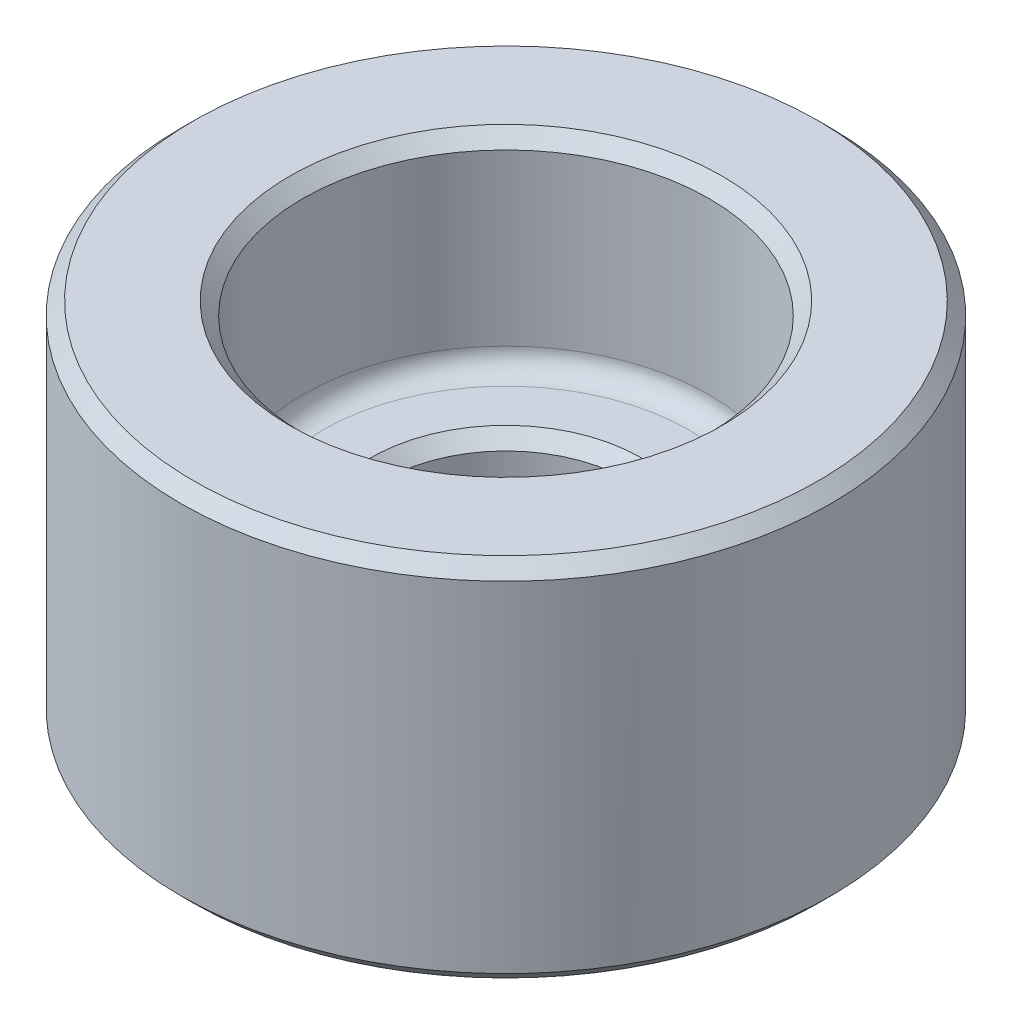
from build123d import *

# Parameters (mm, degrees)
FILLET1_R     = 0.396875
CHAMFER1_SIZE = 0.254


with BuildPart() as part:
    # Sketch1 → Revolve1 (revolve)
    with BuildSketch(Plane.XY):
        Polygon((2.38125, 0), (2.38125, 3.175), (3.96875, 3.175), (3.96875, 7.14375), (6.35, 7.14375), (6.35, 0), align=None)
    revolve(axis=Axis((0, 0, 0), (0, -1, 0)))

    # Fillet1
    fillet1_edges = [part.edges().sort_by_distance(p)[0] for p in [
        (-3.96875, 3.175, 0),
    ]]
    fillet(fillet1_edges, radius=FILLET1_R)

    # Chamfer1
    chamfer1_edges = [part.edges().sort_by_distance(p)[0] for p in [
        (-6.35, 0, 0),
        (-6.35, 7.14375, 0),
        (-3.96875, 7.14375, 0),
        (-2.38125, 3.175, 0),
        (-2.38125, 0, 0),
    ]]
    chamfer(chamfer1_edges, length=CHAMFER1_SIZE)


solid = part.part
